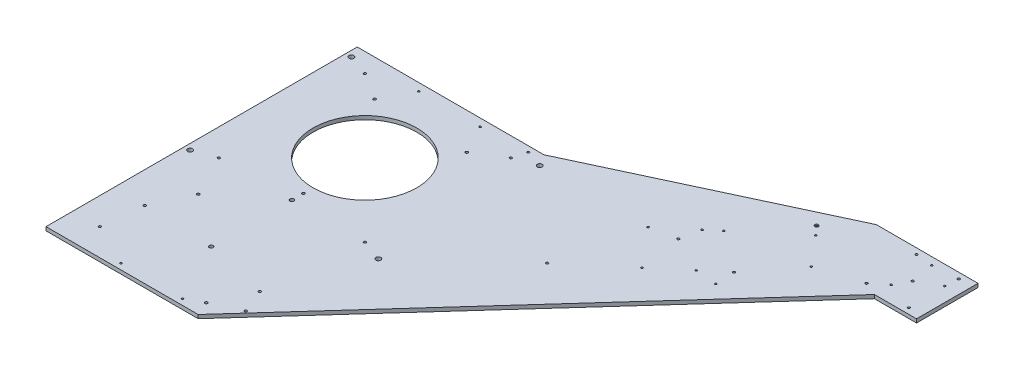
from build123d import *

# Parameters (mm, degrees)
PLATE_OUTLITE_BOSS_EXTRUDE_DEPTH                  = 9.53
BEAM_CLEARANCE_HOLE_REACH                         = 11.53
SKETCH2_R                                         = 135
A_6_2_6_2_DIAMETER_HOLE_D                         = 6.2
A_6_2_6_2_DIAMETER_HOLE_DEPTH                     = 9.53
B_TAP_DRILL_FOR_M6X1_0_TAP_D                      = 5
B_TAP_DRILL_FOR_M6X1_0_TAP_DEPTH                  = 9.53
C_12_5_12_5_DIAMETER_HOLE_D                       = 12.7
C_12_5_12_5_DIAMETER_HOLE_DEPTH                   = 9.53
E_6_2_6_2_DIAMETER_HOLE_D                         = 6.2
E_6_2_6_2_DIAMETER_HOLE_DEPTH                     = 9.53
F_TAP_DRILL_FOR_M8X1_25_TAP_D                     = 6.8
F_TAP_DRILL_FOR_M8X1_25_TAP_DEPTH                 = 9.53
J_6_0_6_DIAMETER_HOLE_D                           = 6
J_6_0_6_DIAMETER_HOLE_DEPTH                       = 9.53
K_10_0_10_DIAMETER_HOLE_D                         = 10
K_10_0_10_DIAMETER_HOLE_DEPTH                     = 9.53
L_6_1MM_HOLE_9_53MM_C_BORE_3_2MM_DEEP_D           = 6.1
L_6_1MM_HOLE_9_53MM_C_BORE_3_2MM_DEEP_DEPTH       = 9.53
L_6_1MM_HOLE_9_53MM_C_BORE_3_2MM_DEEP_CBORE_D     = 9.53
L_6_1MM_HOLE_9_53MM_C_BORE_3_2MM_DEEP_CBORE_DEPTH = 3.2
L_6_1MM_HOLE_9_53MM_C_BORE_3_2MM_DEEP_TIP         = 1.832624888
M_6_0_6_DIAMETER_HOLE_D                           = 6
M_6_0_6_DIAMETER_HOLE_DEPTH                       = 10
M_6_0_6_DIAMETER_HOLE_TIP                         = 1.802581857


with BuildPart() as part:
    # Sketch1 → Plate Outlite - Boss-Extrude (new body)
    with BuildSketch(Plane(origin=(0, 0, 0), x_dir=(1, 0, 0), z_dir=(0, 1, 0))):
        Polygon((-260, 240), (226, 240), (816, 515.1), (1080.6, 515.1), (1080.6, 355.1), (971, 355.1), (136, -570), (-260, -570), align=None)
    extrude(amount=PLATE_OUTLITE_BOSS_EXTRUDE_DEPTH)

    # Sketch2 → Beam Clearance Hole (cut, up to next)
    with BuildSketch(Plane(origin=(0, 9.53, 0), x_dir=(1, 0, 0), z_dir=(0, 1, 0)), mode=Mode.PRIVATE) as beam_clearance_hole_sk1:
        Circle(SKETCH2_R)
    beam_clearance_hole_tool1 = extrude(beam_clearance_hole_sk1.sketch, amount=-BEAM_CLEARANCE_HOLE_REACH, mode=Mode.PRIVATE) & part.part
    add(beam_clearance_hole_tool1.solids().sort_by_distance((0, 9.53, 0))[0], mode=Mode.SUBTRACT)

    # A - Ø6.2 (6.2) Diameter Hole
    with Locations(Plane(origin=(0, 9.53, 0), x_dir=(1, 0, 0), z_dir=(0, 1, 0))):
        with Locations((-190, 190), (190, 190), (190, -190), (-190, -190), (-190, -500), (190, -500)):
            Hole(A_6_2_6_2_DIAMETER_HOLE_D / 2, depth=A_6_2_6_2_DIAMETER_HOLE_DEPTH)

    # B - Tap Drill for M6x1.0 Tap
    with Locations(Plane(origin=(0, 9.53, 0), x_dir=(1, 0, 0), z_dir=(0, 1, 0))):
        with Locations((-80, 220), (80, 220), (524.5, 212.5), (979.9, 495.2), (1043.4, 465.7), (971, 398.8), (761.6, 412), (826.04, 335.57), (684.8, 177.3), (601, 276.7), (608.3, 112.8), (80, -555), (-80, -555), (740.8, 172.5), (631.6, 302.5)):
            Hole(B_TAP_DRILL_FOR_M6X1_0_TAP_D / 2, depth=B_TAP_DRILL_FOR_M6X1_0_TAP_DEPTH)

    # C - Ø12.5 (12.5) Diameter Hole
    with Locations(Plane(origin=(0, 9.53, 0), x_dir=(1, 0, 0), z_dir=(0, 1, 0))):
        with Locations((-245, 210), (-245, -210), (245, -210), (245, 210)):
            Hole(C_12_5_12_5_DIAMETER_HOLE_D / 2, depth=C_12_5_12_5_DIAMETER_HOLE_DEPTH)

    # E - Ø6.2 (6.2) Diameter Hole
    with Locations(Plane(origin=(0, 9.53, 0), x_dir=(1, 0, 0), z_dir=(0, 1, 0))):
        with Locations((935.6, 500.1), (1045.6, 500.1), (1045.6, 370.1), (935.6, 370.1)):
            Hole(E_6_2_6_2_DIAMETER_HOLE_D / 2, depth=E_6_2_6_2_DIAMETER_HOLE_DEPTH)

    # F - Tap Drill for M8x1.25 Tap
    with Locations(Plane(origin=(0, 9.53, 0), x_dir=(1, 0, 0), z_dir=(0, 1, 0))):
        with Locations((-120, 145), (120, 145), (0, -160), (-134.9, -298.7), (-179.1, -393.9), (120.1, -533), (164.4, -437.8)):
            Hole(F_TAP_DRILL_FOR_M8X1_25_TAP_D / 2, depth=F_TAP_DRILL_FOR_M8X1_25_TAP_DEPTH)

    # J - Ø6.0 (6) Diameter Hole
    with Locations(Plane(origin=(0, 9.53, 0), x_dir=(1, 0, 0), z_dir=(0, 1, 0))):
        with Locations((200, 225.1), (474.5, 0), (738.3, 222.4), (590.6, 225.1)):
            Hole(J_6_0_6_DIAMETER_HOLE_D / 2, depth=J_6_0_6_DIAMETER_HOLE_DEPTH)

    # K - Ø10.0 (10) Diameter Hole
    with Locations(Plane(origin=(0, 9.53, 0), x_dir=(1, 0, 0), z_dir=(0, 1, 0))):
        with Locations((0, -190), (0, -400)):
            Hole(K_10_0_10_DIAMETER_HOLE_D / 2, depth=K_10_0_10_DIAMETER_HOLE_DEPTH)

    # L - 6.1mm Hole, 9.53mm C-bore 3.2mm deep
    with Locations(Plane(origin=(0, 9.53, 0), x_dir=(1, 0, 0), z_dir=(0, 1, 0))):
        with Locations((740.6, 435.1)):
            CounterBoreHole(L_6_1MM_HOLE_9_53MM_C_BORE_3_2MM_DEEP_D / 2, L_6_1MM_HOLE_9_53MM_C_BORE_3_2MM_DEEP_CBORE_D / 2, L_6_1MM_HOLE_9_53MM_C_BORE_3_2MM_DEEP_CBORE_DEPTH, depth=L_6_1MM_HOLE_9_53MM_C_BORE_3_2MM_DEEP_DEPTH)
            with Locations((0, 0, -(L_6_1MM_HOLE_9_53MM_C_BORE_3_2MM_DEEP_DEPTH + L_6_1MM_HOLE_9_53MM_C_BORE_3_2MM_DEEP_TIP / 2))):  # 118° drill point
                Cone(0, L_6_1MM_HOLE_9_53MM_C_BORE_3_2MM_DEEP_D / 2, L_6_1MM_HOLE_9_53MM_C_BORE_3_2MM_DEEP_TIP, mode=Mode.SUBTRACT)

    # M - Ø6.0 (6) Diameter Hole
    with Locations(Plane(origin=(0, 9.53, 0), x_dir=(1, 0, 0), z_dir=(0, 1, 0))):
        with Locations((990.6, 435.1)):
            Hole(M_6_0_6_DIAMETER_HOLE_D / 2, depth=M_6_0_6_DIAMETER_HOLE_DEPTH)
            with Locations((0, 0, -(M_6_0_6_DIAMETER_HOLE_DEPTH + M_6_0_6_DIAMETER_HOLE_TIP / 2))):  # 118° drill point
                Cone(0, M_6_0_6_DIAMETER_HOLE_D / 2, M_6_0_6_DIAMETER_HOLE_TIP, mode=Mode.SUBTRACT)


solid = part.part
